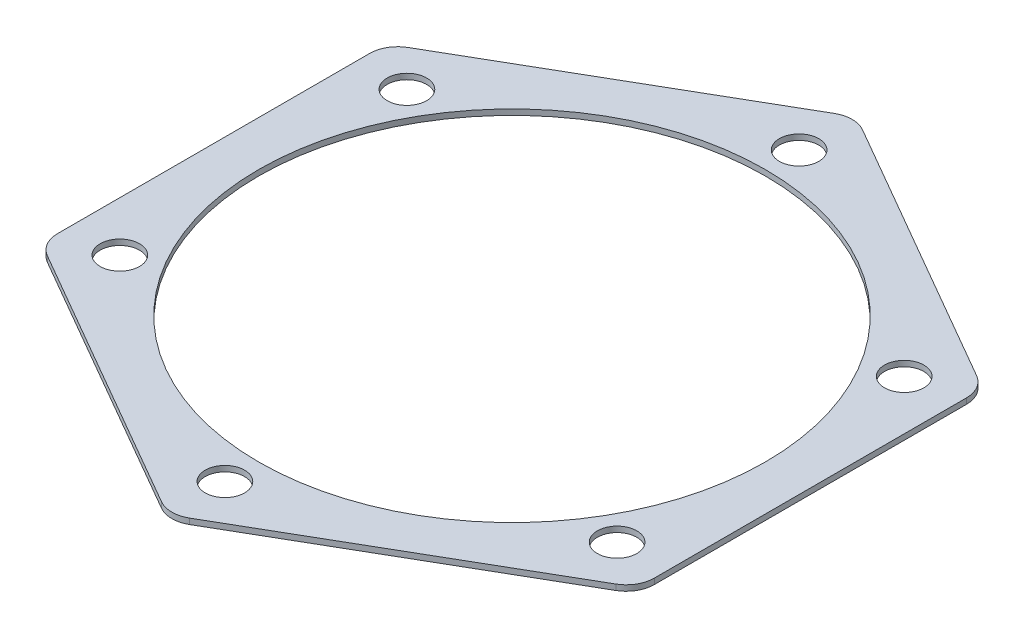
from build123d import *

# Parameters (mm, degrees)
SKETCH1_R           = 45
SKETCH1_R_2         = 3.5
BOSS_EXTRUDE1_DEPTH = 1


with BuildPart() as part:
    # Sketch1 → Boss-Extrude1 (new body)
    with BuildSketch(Plane(origin=(0, 0, 0), x_dir=(1, 0, 0), z_dir=(0, 1, 0))):
        with BuildLine():
            Line((-2.5, 59.755752861), (-50.5, 32.04293994))
            ThreePointArc((-50.5, 32.04293994), (-52.330127019, 30.212812921), (-53, 27.712812921))
            Line((-53, 27.712812921), (-53, -27.712812921))
            ThreePointArc((-53, -27.712812921), (-52.330127019, -30.212812921), (-50.5, -32.04293994))
            Line((-50.5, -32.04293994), (-2.5, -59.755752861))
            ThreePointArc((-2.5, -59.755752861), (0, -60.425625842), (2.5, -59.755752861))
            Line((2.5, -59.755752861), (50.5, -32.04293994))
            ThreePointArc((50.5, -32.04293994), (52.330127019, -30.212812921), (53, -27.712812921))
            Line((53, -27.712812921), (53, 27.712812921))
            ThreePointArc((53, 27.712812921), (52.330127019, 30.212812921), (50.5, 32.04293994))
            Line((50.5, 32.04293994), (2.5, 59.755752861))
            ThreePointArc((2.5, 59.755752861), (0, 60.425625842), (-2.5, 59.755752861))
        make_face()
        Circle(SKETCH1_R, mode=Mode.SUBTRACT)
        with Locations((0, 51)):
            Circle(SKETCH1_R_2, mode=Mode.SUBTRACT)
        with Locations((44.167295593, 25.5)):
            Circle(SKETCH1_R_2, mode=Mode.SUBTRACT)
        with Locations((44.167295593, -25.5)):
            Circle(SKETCH1_R_2, mode=Mode.SUBTRACT)
        with Locations((0, -51)):
            Circle(SKETCH1_R_2, mode=Mode.SUBTRACT)
        with Locations((-44.167295593, -25.5)):
            Circle(SKETCH1_R_2, mode=Mode.SUBTRACT)
        with Locations((-44.167295593, 25.5)):
            Circle(SKETCH1_R_2, mode=Mode.SUBTRACT)
    extrude(amount=BOSS_EXTRUDE1_DEPTH)


solid = part.part
